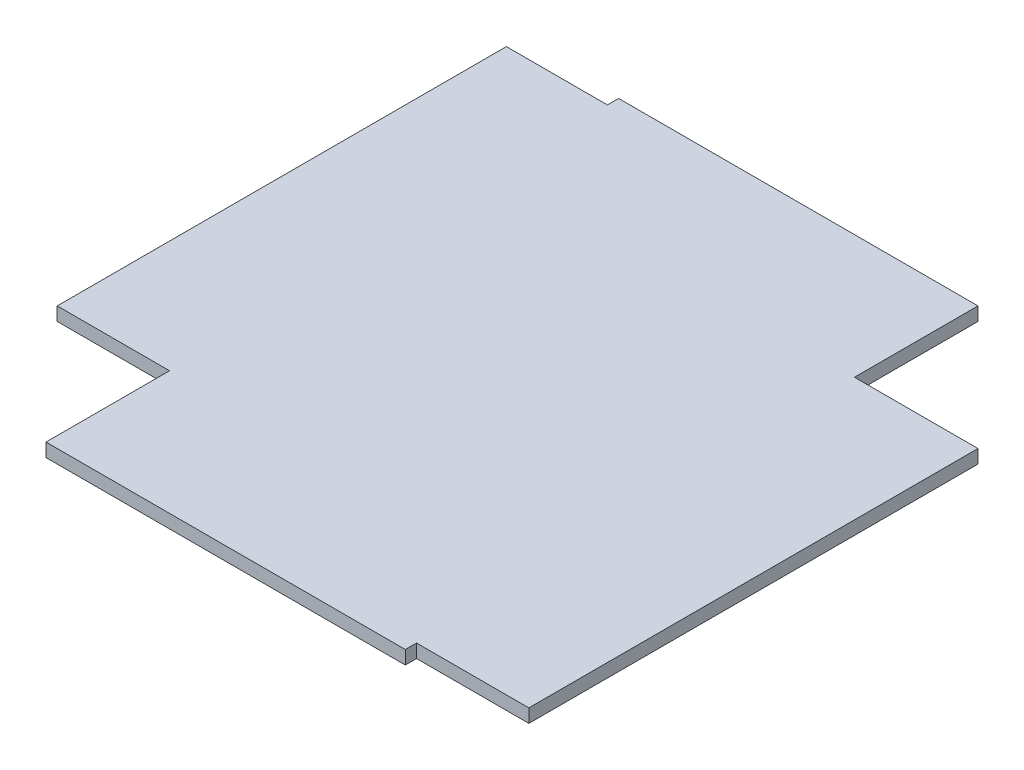
from build123d import *

# Parameters (mm, degrees)
SKETCH1_W           = 150
SKETCH1_H           = 150
BOSS_EXTRUDE1_DEPTH = 6
CUT_EXTRUDE2_DEPTH  = 6
SKETCH3_W           = 55
SKETCH3_H           = 200
BOSS_EXTRUDE3_DEPTH = 6
SKETCH4_W           = 160
SKETCH4_H           = 55
BOSS_EXTRUDE4_DEPTH = 6
SKETCH5_W           = 55
SKETCH5_H           = 200
BOSS_EXTRUDE5_DEPTH = 6
SKETCH6_W           = 160
SKETCH6_H           = 55
BOSS_EXTRUDE6_DEPTH = 6


with BuildPart() as part:
    # Sketch1 → Boss-Extrude1 (new body)
    with BuildSketch(Plane(origin=(0, 0, 0), x_dir=(1, 0, 0), z_dir=(0, 1, 0))):
        Rectangle(SKETCH1_W, SKETCH1_H)
    extrude(amount=BOSS_EXTRUDE1_DEPTH)

    # Sketch2 → Cut-Extrude2 (cut)
    with BuildSketch(Plane(origin=(0, 6, 0), x_dir=(1, 0, 0), z_dir=(0, 1, 0))):
        Polygon((-5, -65), (-5, -5), (-65, -65), align=None)
        Polygon((-10, 0), (-5, 5), (-15, 5), align=None)
        Polygon((-5, 65), (-65, 65), (-5, 5), align=None)
        Polygon((-65, 5), (-15, 5), (-65, 55), align=None)
        Polygon((-10, 0), (-15, 5), (-65, 5), (-65, -5), (-15, -5), align=None)
        Polygon((-5, -5), (-10, 0), (-15, -5), align=None)
        Polygon((-65, -55), (-15, -5), (-65, -5), align=None)
        Polygon((5, 5), (65, 65), (5, 65), align=None)
        Polygon((65, -65), (5, -5), (5, -65), align=None)
        Polygon((15, 5), (5, 5), (10, 0), align=None)
        Polygon((65, 5), (15, 5), (10, 0), (15, -5), (65, -5), align=None)
        Polygon((65, 55), (15, 5), (65, 5), align=None)
        Polygon((15, -5), (10, 0), (5, -5), align=None)
        Polygon((65, -5), (15, -5), (65, -55), align=None)
    extrude(amount=-CUT_EXTRUDE2_DEPTH, mode=Mode.SUBTRACT)

    # Sketch3 → Boss-Extrude3 (add)
    with BuildSketch(Plane(origin=(0, 6, 0), x_dir=(1, 0, 0), z_dir=(0, 1, 0))):
        with Locations((102.5, -25)):
            Rectangle(SKETCH3_W, SKETCH3_H)
        Polygon((65, -65), (5, -5), (5, -65), align=None)
        Polygon((10, 0), (5, -5), (15, -5), (65, -55), (65, 55), (15, 5), (5, 5), align=None)
        Polygon((5, 65), (5, 5), (65, 65), align=None)
        Polygon((-5, -65), (-5, -5), (-65, -65), align=None)
        Polygon((-15, -5), (-5, -5), (-10, 0), (-5, 5), (-15, 5), (-65, 55), (-65, -55), align=None)
        Polygon((-65, 65), (-5, 5), (-5, 65), align=None)
    extrude(amount=-BOSS_EXTRUDE3_DEPTH)

    # Sketch4 → Boss-Extrude4 (add)
    with BuildSketch(Plane(origin=(0, 6, 0), x_dir=(1, 0, 0), z_dir=(0, 1, 0))):
        with Locations((0, -102.5)):
            Rectangle(SKETCH4_W, SKETCH4_H)
    extrude(amount=-BOSS_EXTRUDE4_DEPTH)

    # Sketch5 → Boss-Extrude5 (add)
    with BuildSketch(Plane(origin=(0, 6, 0), x_dir=(1, 0, 0), z_dir=(0, 1, 0))):
        with Locations((-102.5, 25)):
            Rectangle(SKETCH5_W, SKETCH5_H)
    extrude(amount=-BOSS_EXTRUDE5_DEPTH)

    # Sketch6 → Boss-Extrude6 (add)
    with BuildSketch(Plane(origin=(0, 6, 0), x_dir=(1, 0, 0), z_dir=(0, 1, 0))):
        with Locations((-5, 102.5)):
            Rectangle(SKETCH6_W, SKETCH6_H)
    extrude(amount=-BOSS_EXTRUDE6_DEPTH)


solid = part.part
